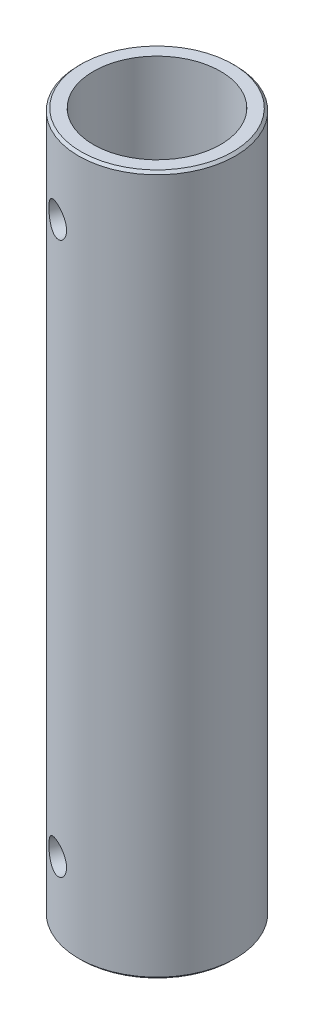
from build123d import *

# Parameters (mm, degrees)
SKETCH1_R               = 7.94
SKETCH1_R_2             = 6.44
BOSS_EXTRUDE1_DEPTH     = 70.91
CHAMFER1_SIZE           = 0.25
SKETCH2_R               = 1.55
CUT_EXTRUDE1_DEPTH      = 5.405594573
CUT_EXTRUDE1_DEPTH_BACK = 17.105594573


with BuildPart() as part:
    # Sketch1 → Boss-Extrude1 (new body)
    with BuildSketch(Plane(origin=(0, 0, 0), x_dir=(1, 0, 0), z_dir=(0, 1, 0))):
        Circle(SKETCH1_R)
        Circle(SKETCH1_R_2, mode=Mode.SUBTRACT)
    extrude(amount=BOSS_EXTRUDE1_DEPTH)

    # Chamfer1
    chamfer1_edges = [part.edges().sort_by_distance(p)[0] for p in [
        (-7.94, 0, 0),
        (-7.94, 70.91, 0),
    ]]
    chamfer(chamfer1_edges, length=CHAMFER1_SIZE)

    # Sketch2 → Cut-Extrude1 (cut, two sides)
    with BuildSketch(Plane(origin=(-2.093493753, 0, 5.462580334), x_dir=(0.933774416, 0, 0.35786218), z_dir=(-0.35786218, 0, 0.933774416))) as cut_extrude1_sk:
        with Locations((0, 63.41)):
            Circle(SKETCH2_R)
        with Locations((0, 7.5)):
            Circle(SKETCH2_R)
    extrude(amount=CUT_EXTRUDE1_DEPTH, mode=Mode.SUBTRACT)
    extrude(cut_extrude1_sk.sketch, amount=-CUT_EXTRUDE1_DEPTH_BACK, mode=Mode.SUBTRACT)


solid = part.part
